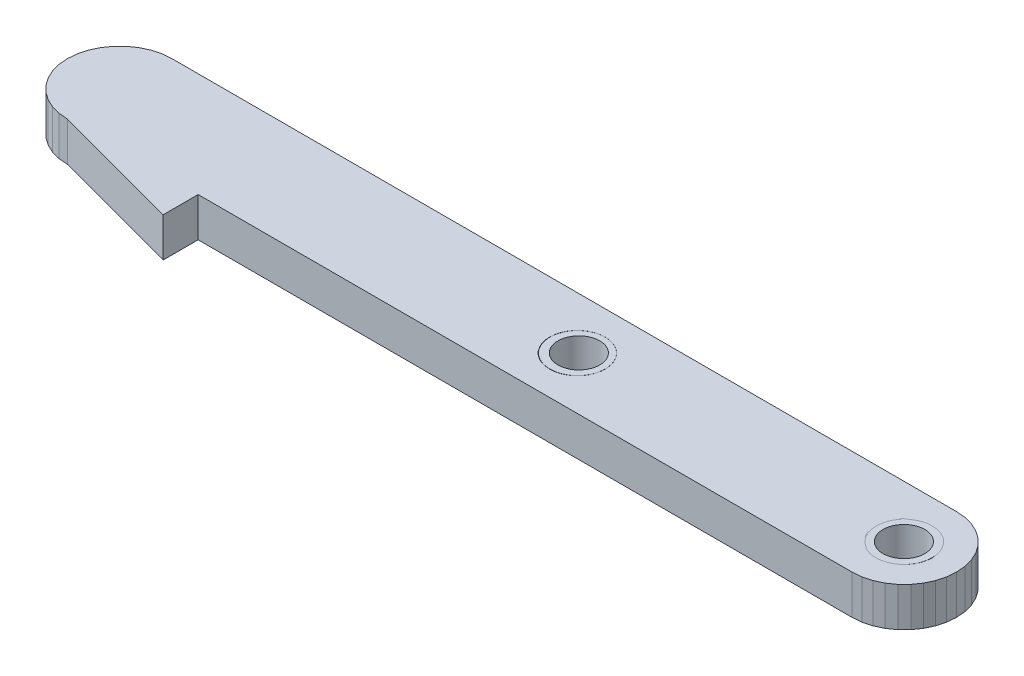
from build123d import *

# Parameters (mm, degrees)
BOSS_EXTRUDE1_DEPTH           = 3.000000026
SKETCH2_R                     = 2.11121725
BOSS_EXTRUDE2_DEPTH           = 3
SKETCH2_R_2                   = 2.149164951
BOSS_EXTRUDE2_2_DEPTH         = 3
SKETCH4_W                     = 1.6
SKETCH4_H                     = 3.000000026
M3_CLEARANCE_HOLE1_AT_2_COUNT = 2
M3_CLEARANCE_HOLE1_AT_2_PITCH = 24.92264996


with BuildPart() as part:
    # Sketch1 → Boss-Extrude1 (new body)
    with BuildSketch(Plane.XZ):
        Polygon((64.00000304, 8.00000038), (14.000002295, 8.00000038), (14.000002295, 10.679492727), (4.000002518, 8.00000038), (3.305409104, 7.939230651), (2.631921321, 7.758770604), (2.000000328, 7.464101538), (1.428849879, 7.064177655), (0.935822725, 6.571150385), (0.535901694, 6.000000052), (0.241231173, 5.368080921), (0.060770661, 4.694593139), (0, 4.00000019), (0.060770661, 3.305407474), (0.241231173, 2.631919459), (0.535901694, 2.000000095), (0.935822725, 1.428849762), (1.428849879, 0.935822492), (2.000000328, 0.535898609), (2.631921321, 0.241229776), (3.305409104, 0.060769264), (4.000002518, 0), (64.00000304, 0), (64.694598317, 0.060769264), (65.3680861, 0.241229776), (65.999999642, 0.535898609), (66.5711537, 0.935822492), (67.06418097, 1.428849762), (67.464098334, 2.000000095), (67.758768797, 2.631919459), (67.93923676, 3.305407474), (68.000003695, 4.00000019), (67.93923676, 4.694593139), (67.758768797, 5.368080921), (67.464098334, 6.000000052), (67.06418097, 6.571150385), (66.5711537, 7.064177655), (65.999999642, 7.464101538), (65.3680861, 7.758770604), (64.694598317, 7.939230651), align=None)
        Polygon((62.634080648, 2.372155897), (62.372155488, 2.634076402), (62.159698457, 2.937500132), (62.003154308, 3.273207461), (61.907283962, 3.630997846), (61.875000596, 4.00000019), (61.907283962, 4.369002767), (62.003154308, 4.726793151), (62.159698457, 5.062500015), (62.372155488, 5.365923978), (62.634080648, 5.627844483), (62.937498093, 5.840304308), (63.273206353, 5.99684706), (63.630998135, 6.09271694), (64.00000304, 6.125000305), (64.369007945, 6.09271694), (64.726792276, 5.99684706), (65.062500536, 5.840304308), (65.365925431, 5.627844483), (65.627843142, 5.365923978), (65.840303898, 5.062500015), (65.996848047, 4.726793151), (66.092714667, 4.369002767), (66.125005484, 4.00000019), (66.092714667, 3.630997846), (65.996848047, 3.273207461), (65.840303898, 2.937500132), (65.627843142, 2.634076402), (65.365925431, 2.372155897), (65.062500536, 2.159696072), (64.726792276, 2.00315332), (64.369007945, 1.907283673), (64.00000304, 1.875000075), (63.630998135, 1.907283673), (63.273206353, 2.00315332), (62.937498093, 2.159696072), align=None, mode=Mode.SUBTRACT)
        Polygon((38.273207843, 5.99684706), (38.630999625, 6.09271694), (39.000000805, 6.125000305), (39.36900571, 6.09271694), (39.726793766, 5.99684706), (40.062502027, 5.840304308), (40.365926921, 5.627844483), (40.627844632, 5.365923978), (40.840305388, 5.062500015), (40.996849537, 4.726793151), (41.092719883, 4.369002767), (41.125003248, 4.00000019), (41.092719883, 3.630997846), (40.996849537, 3.273207461), (40.840305388, 2.937500132), (40.627844632, 2.634076402), (40.365926921, 2.372155897), (40.062502027, 2.159696072), (39.726793766, 2.00315332), (39.36900571, 1.907283673), (39.000000805, 1.875000075), (38.630999625, 1.907283673), (38.273207843, 2.00315332), (37.937503308, 2.159696072), (37.634078413, 2.372155897), (37.372156978, 2.634076402), (37.159696221, 2.937500132), (37.003155798, 3.273207461), (36.907285452, 3.630997846), (36.875002086, 4.00000019), (36.907285452, 4.369002767), (37.003155798, 4.726793151), (37.159696221, 5.062500015), (37.372156978, 5.365923978), (37.634078413, 5.627844483), (37.937503308, 5.840304308), align=None, mode=Mode.SUBTRACT)
    extrude(amount=-BOSS_EXTRUDE1_DEPTH)


with BuildPart() as body_2:
    # Sketch2 → Boss-Extrude2 (new body)
    with BuildSketch(Plane(origin=(0, 3.000000026, 0), x_dir=(1, 0, 0), z_dir=(0, 1, 0))):
        with Locations((39.003749175, -3.994556906)):
            Circle(SKETCH2_R)
    extrude(amount=-BOSS_EXTRUDE2_DEPTH)

    # Sketch4 → M3 Clearance Hole1 (revolve, cut)
    with BuildSketch(Plane(origin=(39.042582184, 3.000000026, 3.931498861), x_dir=(0, 0, 1), z_dir=(1, 0, 0))):
        with Locations((0.8, 1.500000013)):
            Rectangle(SKETCH4_W, SKETCH4_H)
    m3_clearance_hole1 = revolve(axis=Axis((39.042582184, 9.350000026, 3.931498861), (0, -1, 0)), mode=Mode.SUBTRACT)


with BuildPart() as body_3:
    # Sketch2 → Boss-Extrude2 2 (new body)
    with BuildSketch(Plane(origin=(0, 3.000000026, 0), x_dir=(1, 0, 0), z_dir=(0, 1, 0))):
        with Locations((63.965152371, -3.994556906)):
            Circle(SKETCH2_R_2)
    extrude(amount=-BOSS_EXTRUDE2_2_DEPTH)

    # M3 Clearance Hole1 at 2: M3 Clearance Hole1 ×2
    with Locations(*[Vector(0.999996799, 0, 0.00253015) * (i * M3_CLEARANCE_HOLE1_AT_2_PITCH) for i in range(1, M3_CLEARANCE_HOLE1_AT_2_COUNT)]):
        add(m3_clearance_hole1, mode=Mode.SUBTRACT)


solid = Compound([part.part, body_2.part, body_3.part])
